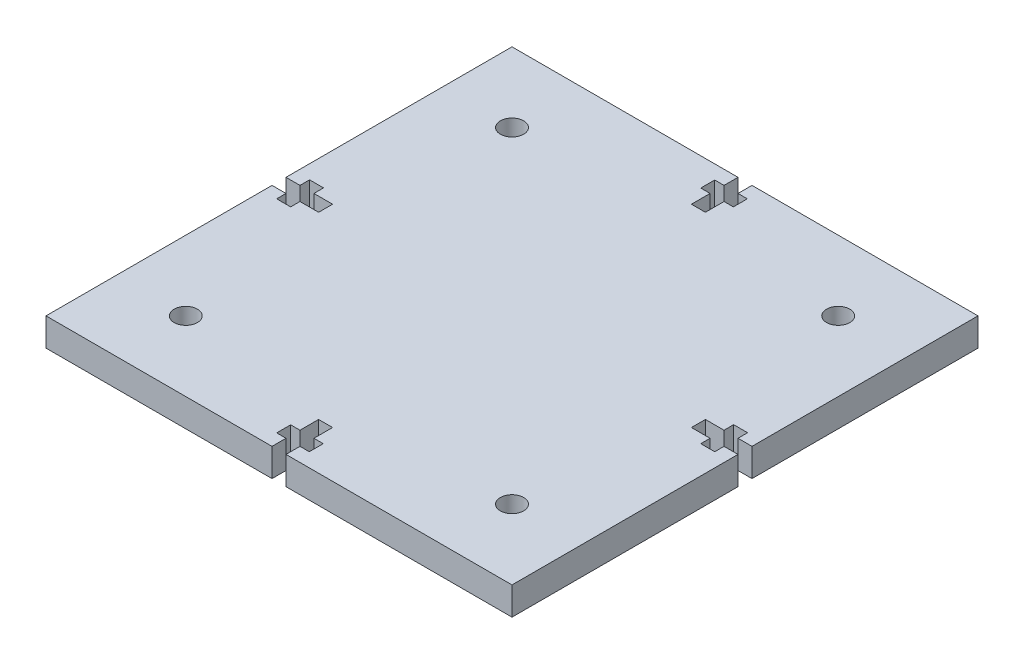
from build123d import *

# Parameters (mm, degrees)
SKETCH1_W           = 100
SKETCH1_H           = 100
BOSS_EXTRUDE1_DEPTH = 6
CUT_EXTRUDE1_DEPTH  = 7
SKETCH4_R           = 2.5
CUT_EXTRUDE3_DEPTH  = 7
CUT_EXTRUDE4_DEPTH  = 10


with BuildPart() as part:
    # Sketch1 → Boss-Extrude1 (new body)
    with BuildSketch(Plane(origin=(0, 0, 0), x_dir=(1, 0, 0), z_dir=(0, 1, 0))):
        with Locations((50, -50)):
            Rectangle(SKETCH1_W, SKETCH1_H)
    extrude(amount=BOSS_EXTRUDE1_DEPTH)

    # Sketch2 → Cut-Extrude1 (cut, through all)
    with BuildSketch(Plane(origin=(0, 6, 0), x_dir=(1, 0, 0), z_dir=(0, 1, 0))):
        Polygon((48.5, 0), (51.5, 0), (51.5, -3), (53.5, -3), (53.5, -6), (51.5, -6), (51.5, -10), (48.5, -10), (48.5, -6), (46.5, -6), (46.5, -3), (48.5, -3), align=None)
        Polygon((48.5, -100), (48.5, -97), (46.5, -97), (46.5, -94), (48.5, -94), (48.5, -90), (51.5, -90), (51.5, -94), (53.5, -94), (53.5, -97), (51.5, -97), (51.5, -100), align=None)
    extrude(amount=-CUT_EXTRUDE1_DEPTH, mode=Mode.SUBTRACT)

    # Sketch4 → Cut-Extrude3 (cut, through all)
    with BuildSketch(Plane(origin=(0, 0, 0), x_dir=(-1, 0, 0), z_dir=(0, -1, 0))):
        with Locations((-15, -85)):
            Circle(SKETCH4_R)
        with Locations((-85, -85)):
            Circle(SKETCH4_R)
        with Locations((-85, -15)):
            Circle(SKETCH4_R)
        with Locations((-15, -15)):
            Circle(SKETCH4_R)
    extrude(amount=-CUT_EXTRUDE3_DEPTH, mode=Mode.SUBTRACT)

    # Sketch5 → Cut-Extrude4 (cut)
    with BuildSketch(Plane.XZ):
        Polygon((0, 51.193613504), (0, 50), (0, 48.5), (3, 48.5), (3, 46.439353032), (6, 46.439353032), (6, 48.5), (10, 48.5), (10, 50), (10, 51.5), (6, 51.5), (6, 53.5), (3, 53.5), (3, 51.5), (0, 51.5), align=None)
        Polygon((100, 48.5), (100, 50), (100, 51.5), (97, 51.5), (97, 53.5), (94, 53.5), (94, 51.5), (90, 51.5), (90, 50), (90, 48.5), (94, 48.5), (94, 46.439353032), (97, 46.439353032), (97, 48.5), align=None)
    extrude(amount=-CUT_EXTRUDE4_DEPTH, mode=Mode.SUBTRACT)


solid = part.part
